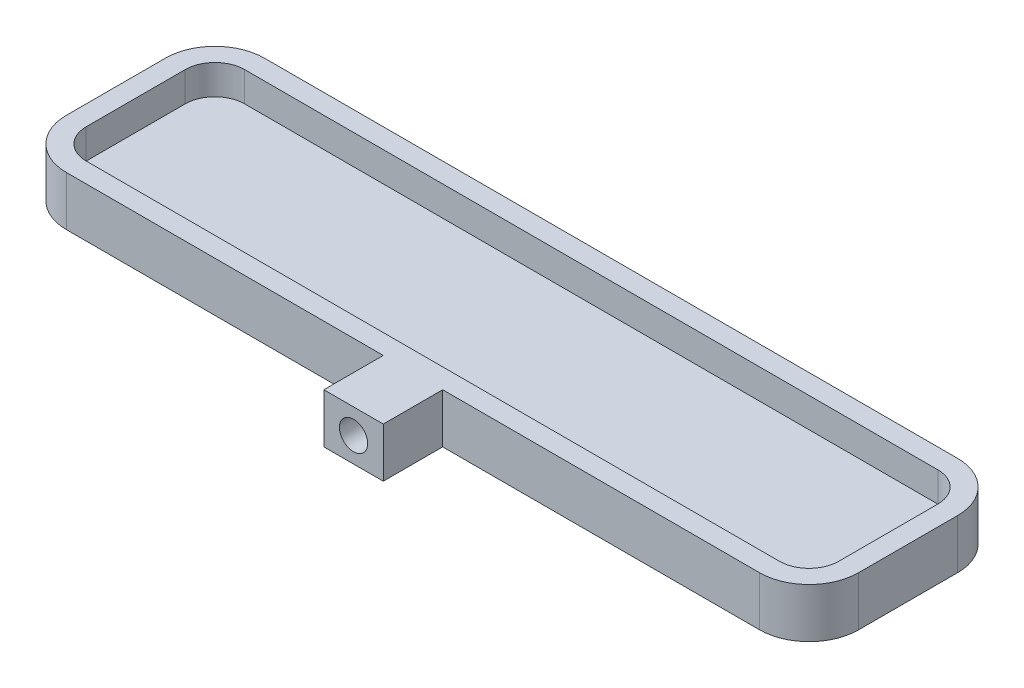
from build123d import *

# Parameters (mm, degrees)
SKETCH1_W           = 80
SKETCH1_H           = 20
BOSS_EXTRUDE1_DEPTH = 5
FILLET1_R           = 5
SHELL1_T            = -2
SKETCH2_W           = 6
SKETCH2_H           = 5
BOSS_EXTRUDE2_DEPTH = 6
SKETCH3_R           = 1.425
CUT_EXTRUDE1_DEPTH  = 4


with BuildPart() as part:
    # Sketch1 → Boss-Extrude1 (new body)
    with BuildSketch(Plane(origin=(0, 0, 0), x_dir=(1, 0, 0), z_dir=(0, 1, 0))):
        Rectangle(SKETCH1_W, SKETCH1_H)
    extrude(amount=BOSS_EXTRUDE1_DEPTH)

    # Fillet1
    fillet1_edges = [part.edges().sort_by_distance(p)[0] for p in [
        (-40, 2.5, -10),
        (40, 2.5, -10),
        (40, 2.5, 10),
        (-40, 2.5, 10),
    ]]
    fillet(fillet1_edges, radius=FILLET1_R)

    # Shell1
    shell1_openings = [part.faces().sort_by_distance(p)[0] for p in [
        (0, 5, 0),
    ]]
    offset(amount=SHELL1_T, openings=shell1_openings, kind=Kind.INTERSECTION)

    # Sketch2 → Boss-Extrude2 (add)
    with BuildSketch(Plane.XY.offset(10)):
        with Locations((0, 2.5)):
            Rectangle(SKETCH2_W, SKETCH2_H)
    extrude(amount=BOSS_EXTRUDE2_DEPTH)

    # Sketch3 → Cut-Extrude1 (cut)
    with BuildSketch(Plane.XY.offset(16)):
        with Locations((0, 2.5)):
            Circle(SKETCH3_R)
    extrude(amount=-CUT_EXTRUDE1_DEPTH, mode=Mode.SUBTRACT)


solid = part.part
